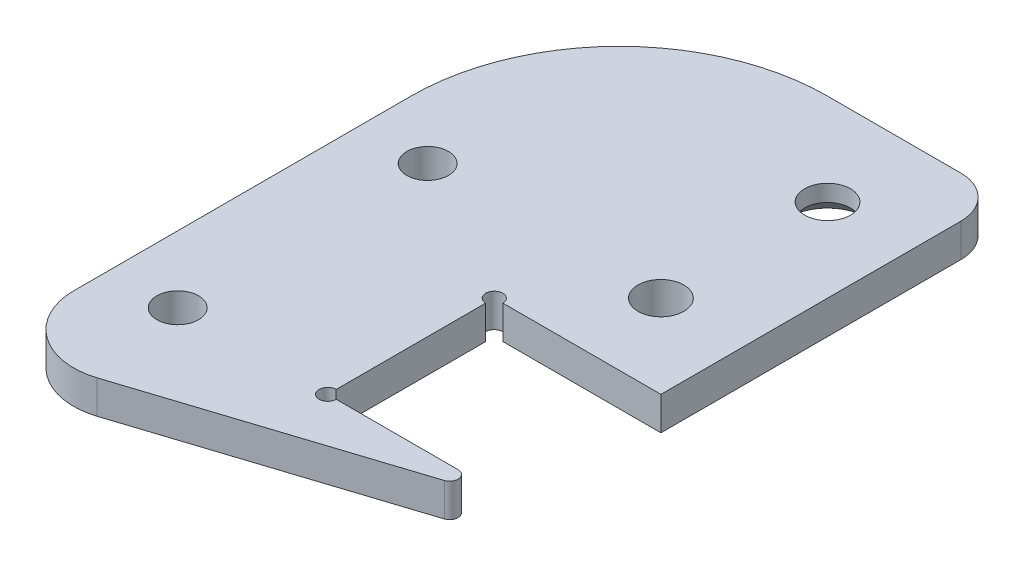
from build123d import *

# Parameters (mm, degrees)
SKETCH_1_R          = 2.75
SKETCH_1_R_2        = 2.5
EXTRUDE_1_DEPTH     = 4
CHAMFER_2_SIZE      = 2
SKETCH_2_R          = 1.025
CUT_EXTRUDE_1_DEPTH = 5


with BuildPart() as part:
    # 草图1 → 凸台-拉伸1 (new body)
    with BuildSketch(Plane(origin=(0, 0, 0), x_dir=(1, 0, 0), z_dir=(0, 1, 0))):
        with BuildLine():
            Line((38, -4.5), (18, -4.5))
            Line((18, -4.5), (18, -24.5))
            Line((18, -24.5), (33.644053232, -24.5))
            ThreePointArc((33.644053232, -24.5), (34.63190154, -25.344578889), (33.951118195, -26.451688557))
            Line((33.951118195, -26.451688557), (2.456519701, -36.613508453))
            ThreePointArc((2.456519701, -36.613508453), (-4.708919324, -35.467308467), (-8, -29))
            Line((-8, -29), (-8, 11.5))
            ThreePointArc((-8, 11.5), (-0.67766953, 29.17766953), (17, 36.5))
            Line((17, 36.5), (33, 36.5))
            ThreePointArc((33, 36.5), (36.535533906, 35.035533906), (38, 31.5))
            Line((38, 31.5), (38, -4.5))
        make_face()
        with Locations((28, 5.5)):
            Circle(SKETCH_1_R, mode=Mode.SUBTRACT)
        with Locations((28, 25.5)):
            Circle(SKETCH_1_R, mode=Mode.SUBTRACT)
        with Locations((0, 5.5)):
            Circle(SKETCH_1_R_2, mode=Mode.SUBTRACT)
        with Locations((0, -24.5)):
            Circle(SKETCH_1_R_2, mode=Mode.SUBTRACT)
    extrude(amount=EXTRUDE_1_DEPTH)

    # 倒角2
    chamfer_2_edges = [part.edges().sort_by_distance(p)[0] for p in [
        (25.25, 0, -25.5),
    ]]
    chamfer(chamfer_2_edges, length=CHAMFER_2_SIZE)

    # 草图2 → 切除-拉伸1 (cut, symmetric)
    with BuildSketch(Plane(origin=(0, 4, 0), x_dir=(1, 0, 0), z_dir=(0, 1, 0))):
        with Locations((18, -4.5)):
            Circle(SKETCH_2_R)
        with Locations((18, -24.5)):
            Circle(SKETCH_2_R)
    extrude(amount=CUT_EXTRUDE_1_DEPTH, both=True, mode=Mode.SUBTRACT)


solid = part.part
